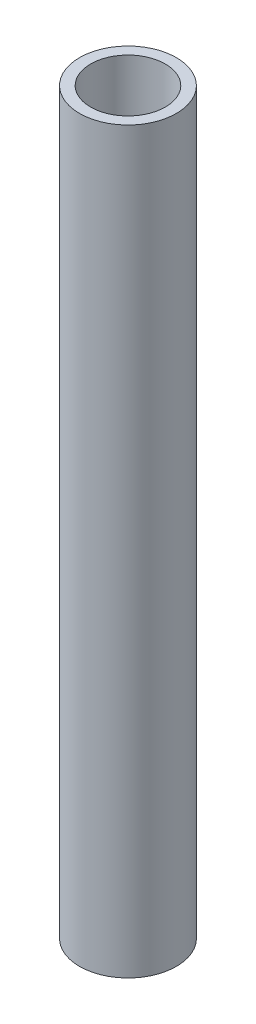
from build123d import *

# Parameters (mm, degrees)
SKETCH1_R           = 2.85
BOSS_EXTRUDE1_DEPTH = 43.5
SKETCH2_R           = 2.2
CUT_EXTRUDE1_DEPTH  = 40


with BuildPart() as part:
    # Sketch1 → Boss-Extrude1 (new body)
    with BuildSketch(Plane(origin=(0, 0, 0), x_dir=(1, 0, 0), z_dir=(0, 1, 0))):
        Circle(SKETCH1_R)
    extrude(amount=BOSS_EXTRUDE1_DEPTH)

    # Sketch2 → Cut-Extrude1 (cut)
    with BuildSketch(Plane(origin=(0, 43.5, 0), x_dir=(1, 0, 0), z_dir=(0, 1, 0))):
        Circle(SKETCH2_R)
    extrude(amount=-CUT_EXTRUDE1_DEPTH, mode=Mode.SUBTRACT)


solid = part.part
